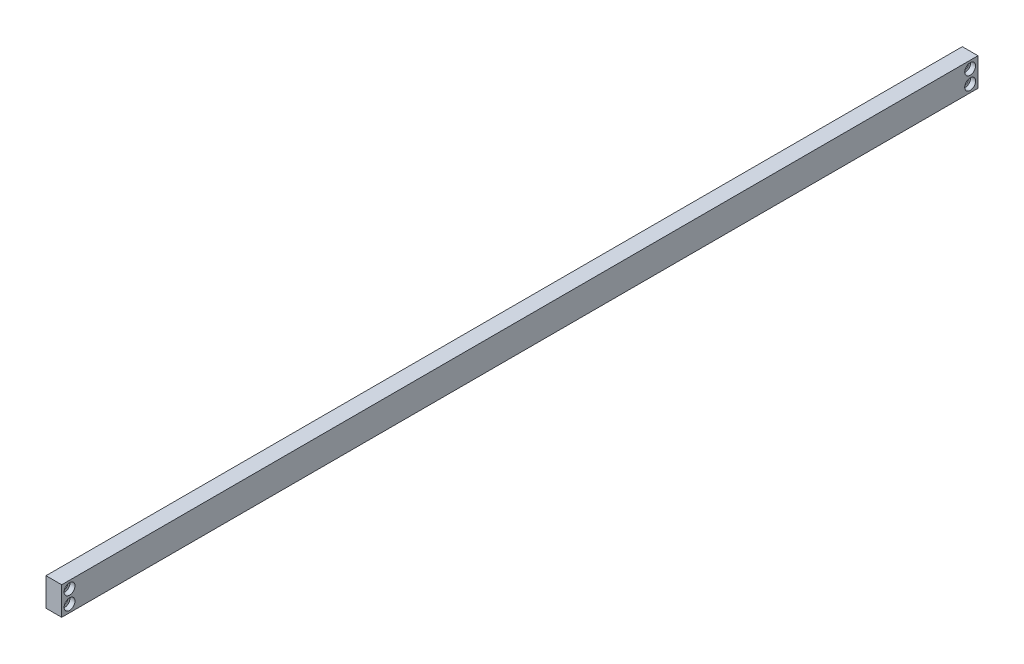
from build123d import *

# Parameters (mm, degrees)
SKETCH1_W                      = 6.35
SKETCH1_H                      = 11.43
BOSS_EXTRUDE1_DEPTH            = 370.84
CBORE_FOR_M2_SHCS2_D           = 2.4
CBORE_FOR_M2_SHCS2_CBORE_D     = 4.4
CBORE_FOR_M2_SHCS2_CBORE_DEPTH = 2


with BuildPart() as part:
    # Sketch1 → Boss-Extrude1 (new body)
    with BuildSketch(Plane.XY):
        with Locations((3.175, 5.715)):
            Rectangle(SKETCH1_W, SKETCH1_H)
    extrude(amount=-BOSS_EXTRUDE1_DEPTH)

    # CBORE for M2 SHCS2 (through all)
    with Locations(Plane(origin=(6.35, 0, 0), x_dir=(0, 0, -1), z_dir=(1, 0, 0))):
        with Locations((3.175, 8.382), (3.175, 3.048)):
            cbore_for_m2_shcs2 = CounterBoreHole(CBORE_FOR_M2_SHCS2_D / 2, CBORE_FOR_M2_SHCS2_CBORE_D / 2, CBORE_FOR_M2_SHCS2_CBORE_DEPTH)

    # Mirror2: CBORE for M2 SHCS2 across plane
    add(cbore_for_m2_shcs2.mirror(Plane.XY.offset(-185.42)), mode=Mode.SUBTRACT)


solid = part.part
